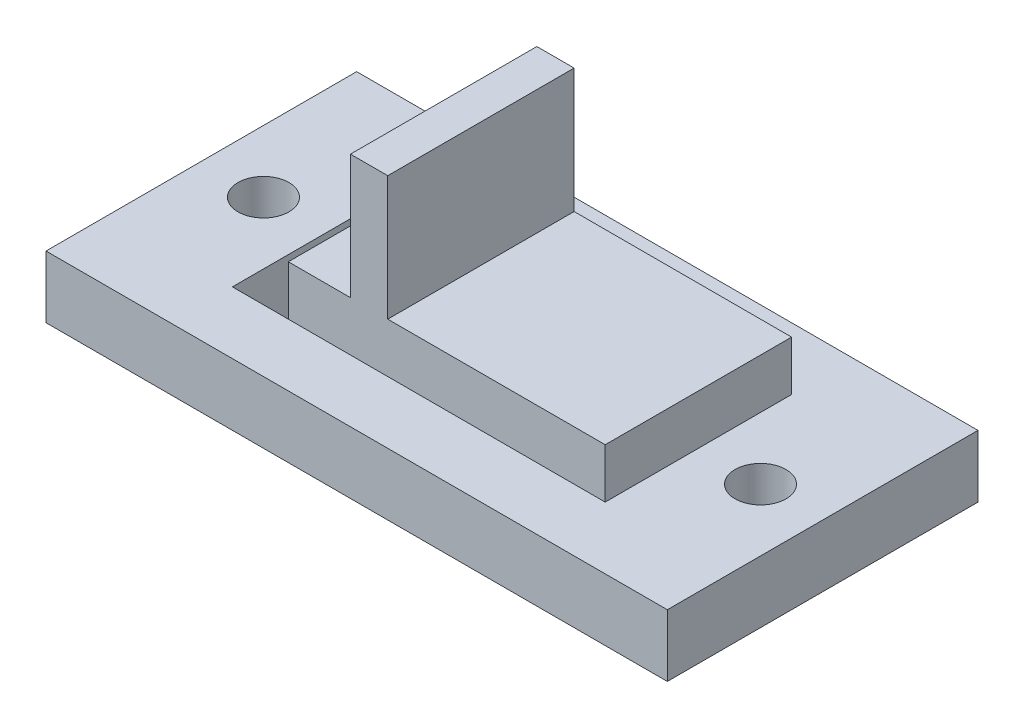
from build123d import *

# Parameters (mm, degrees)
SKETCH1_W           = 25.4
SKETCH1_H           = 12.7
BOSS_EXTRUDE1_DEPTH = 2.54
SKETCH2_W           = 15.24
SKETCH2_H           = 7.62
BOSS_EXTRUDE2_DEPTH = 2.032
SKETCH3_R           = 1.0414
CUT_EXTRUDE1_DEPTH  = 5.572
SKETCH4_W           = 2.286
SKETCH4_H           = 7.62
CUT_EXTRUDE2_DEPTH  = 4.572
SKETCH5_W           = 1.524
SKETCH5_H           = 7.62
BOSS_EXTRUDE3_DEPTH = 5.08


with BuildPart() as part:
    # Sketch1 → Boss-Extrude1 (new body)
    with BuildSketch(Plane(origin=(0, 0, 0), x_dir=(1, 0, 0), z_dir=(0, 1, 0))):
        Rectangle(SKETCH1_W, SKETCH1_H)
    extrude(amount=BOSS_EXTRUDE1_DEPTH)

    # Sketch2 → Boss-Extrude2 (add)
    with BuildSketch(Plane(origin=(0, 2.54, 0), x_dir=(1, 0, 0), z_dir=(0, 1, 0))):
        Rectangle(SKETCH2_W, SKETCH2_H)
    extrude(amount=BOSS_EXTRUDE2_DEPTH)

    # Sketch3 → Cut-Extrude1 (cut, through all)
    with BuildSketch(Plane.XZ):
        with Locations((-10.16, 0)):
            Circle(SKETCH3_R)
        with Locations((10.16, 0)):
            Circle(SKETCH3_R)
    extrude(amount=-CUT_EXTRUDE1_DEPTH, mode=Mode.SUBTRACT)

    # Sketch4 → Cut-Extrude2 (cut)
    with BuildSketch(Plane(origin=(0, 4.572, 0), x_dir=(1, 0, 0), z_dir=(0, 1, 0))):
        with Locations((-6.477, 0)):
            Rectangle(SKETCH4_W, SKETCH4_H)
    extrude(amount=-CUT_EXTRUDE2_DEPTH, mode=Mode.SUBTRACT)

    # Sketch5 → Boss-Extrude3 (add)
    with BuildSketch(Plane(origin=(0, 4.572, 0), x_dir=(1, 0, 0), z_dir=(0, 1, 0))):
        with Locations((-2.032, 0)):
            Rectangle(SKETCH5_W, SKETCH5_H)
    extrude(amount=BOSS_EXTRUDE3_DEPTH)


solid = part.part
